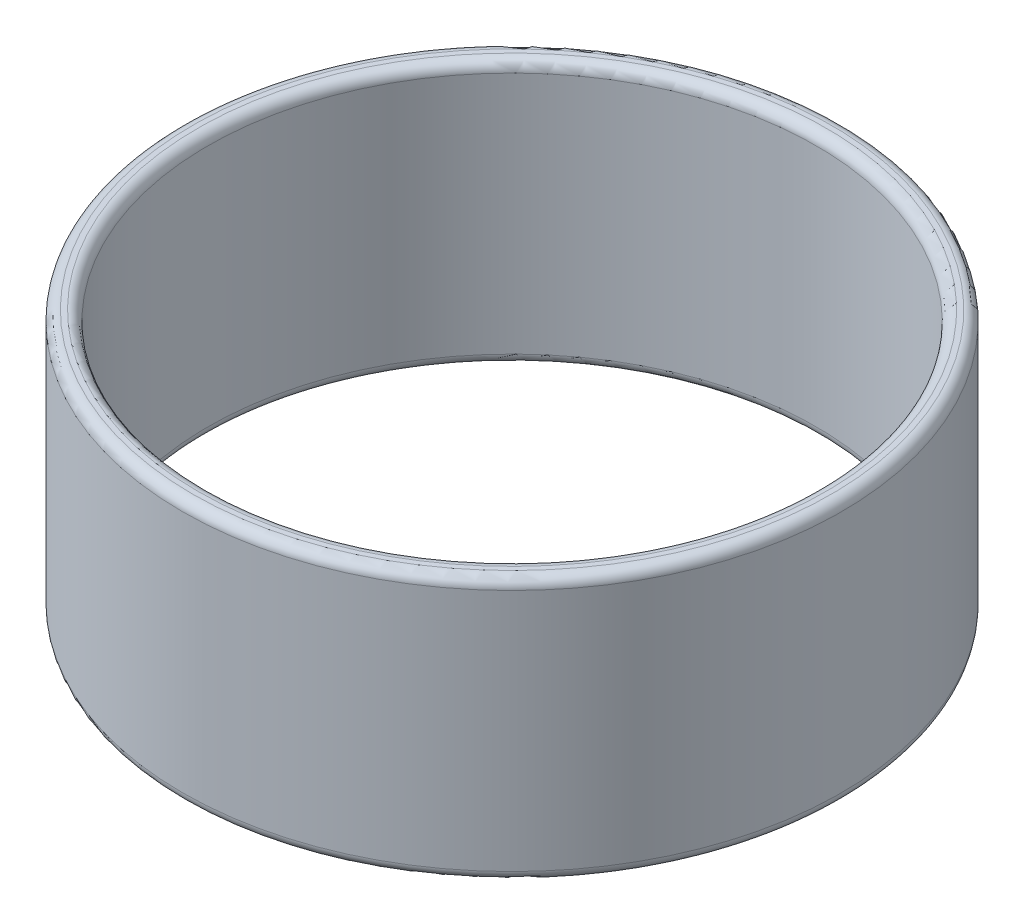
from build123d import *

# Parameters (mm, degrees)
SKETCH_1_R      = 32.5
SKETCH_1_R_2    = 30
EXTRUDE_1_DEPTH = 26
FILLET_1_R      = 1


with BuildPart() as part:
    # 草图1 → 凸台-拉伸1 (new body)
    with BuildSketch(Plane(origin=(0, 0, 0), x_dir=(1, 0, 0), z_dir=(0, 1, 0))):
        Circle(SKETCH_1_R)
        Circle(SKETCH_1_R_2, mode=Mode.SUBTRACT)
    extrude(amount=EXTRUDE_1_DEPTH)

    # 圆角1
    fillet_1_edges = [part.edges().sort_by_distance(p)[0] for p in [
        (-32.5, 0, 0),
        (-32.5, 26, 0),
        (-30, 0, 0),
        (-30, 26, 0),
    ]]
    fillet(fillet_1_edges, radius=FILLET_1_R)


solid = part.part
